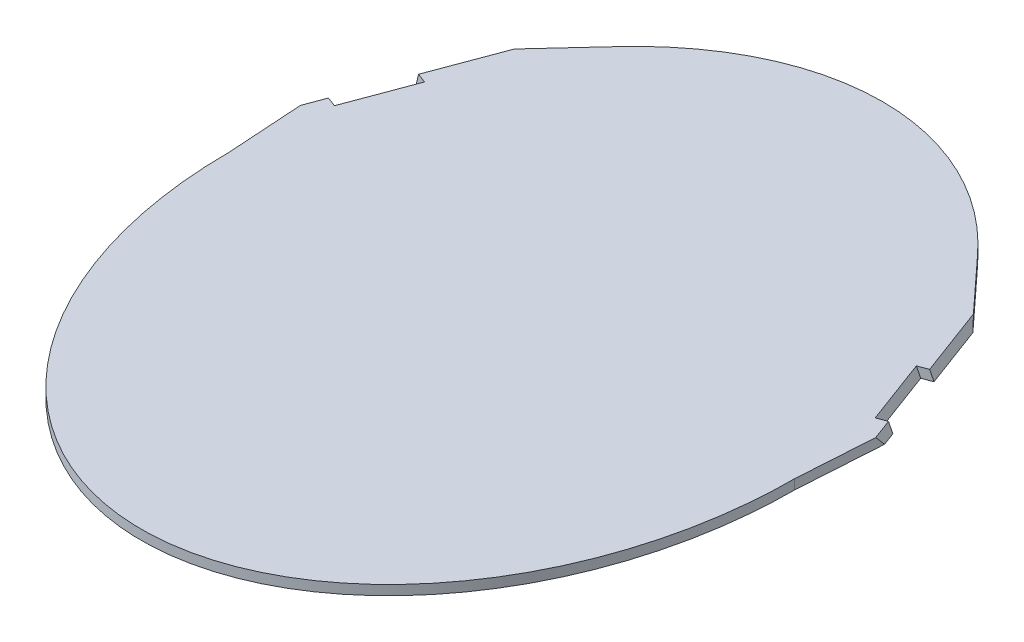
from build123d import *

# Parameters (mm, degrees)
SKETCH1_RX          = 380
SKETCH1_RY          = 290
BOSS_EXTRUDE1_DEPTH = 10
BOSS_EXTRUDE2_DEPTH = 10
CUT_EXTRUDE1_DEPTH  = 10
SKETCH8_W           = 355.795250099
SKETCH8_H           = 262.515596516
CUT_EXTRUDE2_DEPTH  = 102.013832803


with BuildPart() as part:
    # Sketch1 → Boss-Extrude1 (new body)
    with BuildSketch(Plane(origin=(0, 0, 0), x_dir=(1, 0, 0), z_dir=(0, 1, 0))):
        with Locations(Location((0, 0), (0, 0, 90))):
            Ellipse(SKETCH1_RX, SKETCH1_RY)
    extrude(amount=BOSS_EXTRUDE1_DEPTH)

    # Sketch2 → Boss-Extrude2 (add)
    with BuildSketch(Plane(origin=(0, 10, 0), x_dir=(1, 0, 0), z_dir=(0, 1, 0))):
        Polygon((287.228032818, 98.993347022), (277.229646496, 95.262936552), (290, 0), (296.597160239, 102.488980208), align=None)
        Polygon((-296.597160239, 102.488980208), (-290, 0), (-277.229646496, 95.262936552), (-287.228032818, 98.993347022), align=None)
        Polygon((244.797124663, 227.718261487), (188.989530622, 288.225103524), (257.336277473, 164.50388217), (262.120047497, 166.288712763), (271.489174918, 169.784345949), (266.534927877, 209.025181731), align=None)
        Polygon((-266.534927877, 209.025181731), (-271.489174918, 169.784345949), (-262.120047497, 166.288712763), (-257.336277473, 164.50388217), (-188.989530622, 288.225103524), (-244.797124663, 227.718261487), align=None)
    extrude(amount=-BOSS_EXTRUDE2_DEPTH)

    # Sketch4 → Cut-Extrude1 (cut)
    with BuildSketch(Plane(origin=(256.485650454, 95.695117721, -95.695117721), x_dir=(-0.309165432, -0.11535001, -0.943986817), z_dir=(0.884433277, 0.329983165, -0.329983165))):
        Polygon((4.647435865, -100.404384349), (0.972491464, -70.555212825), (72.260950701, -61.778382153), (74.730936612, -81.840463395), (75.935895102, -91.627553677), align=None)
    cut_extrude1 = extrude(amount=-CUT_EXTRUDE1_DEPTH, mode=Mode.SUBTRACT)

    # Mirror1: Cut-Extrude1 across plane
    add(cut_extrude1.mirror(Plane(origin=(0, 0, 0), x_dir=(0, 0, 1), z_dir=(1, 0, 0))), mode=Mode.SUBTRACT)

    # Sketch8 → Cut-Extrude2 (cut, through all)
    with BuildSketch(Plane(origin=(256.485650454, 95.695117721, -95.695117721), x_dir=(-0.309165432, -0.11535001, -0.943986817), z_dir=(0.884433277, 0.329983165, -0.329983165))):
        with Locations((60.595009972, -108.189381189)):
            Rectangle(SKETCH8_W, SKETCH8_H)
    cut_extrude2 = extrude(amount=CUT_EXTRUDE2_DEPTH, mode=Mode.SUBTRACT)

    # Mirror2: Cut-Extrude2 across plane
    add(cut_extrude2.mirror(Plane(origin=(0, 0, 0), x_dir=(0, 0, 1), z_dir=(1, 0, 0))), mode=Mode.SUBTRACT)


solid = part.part
